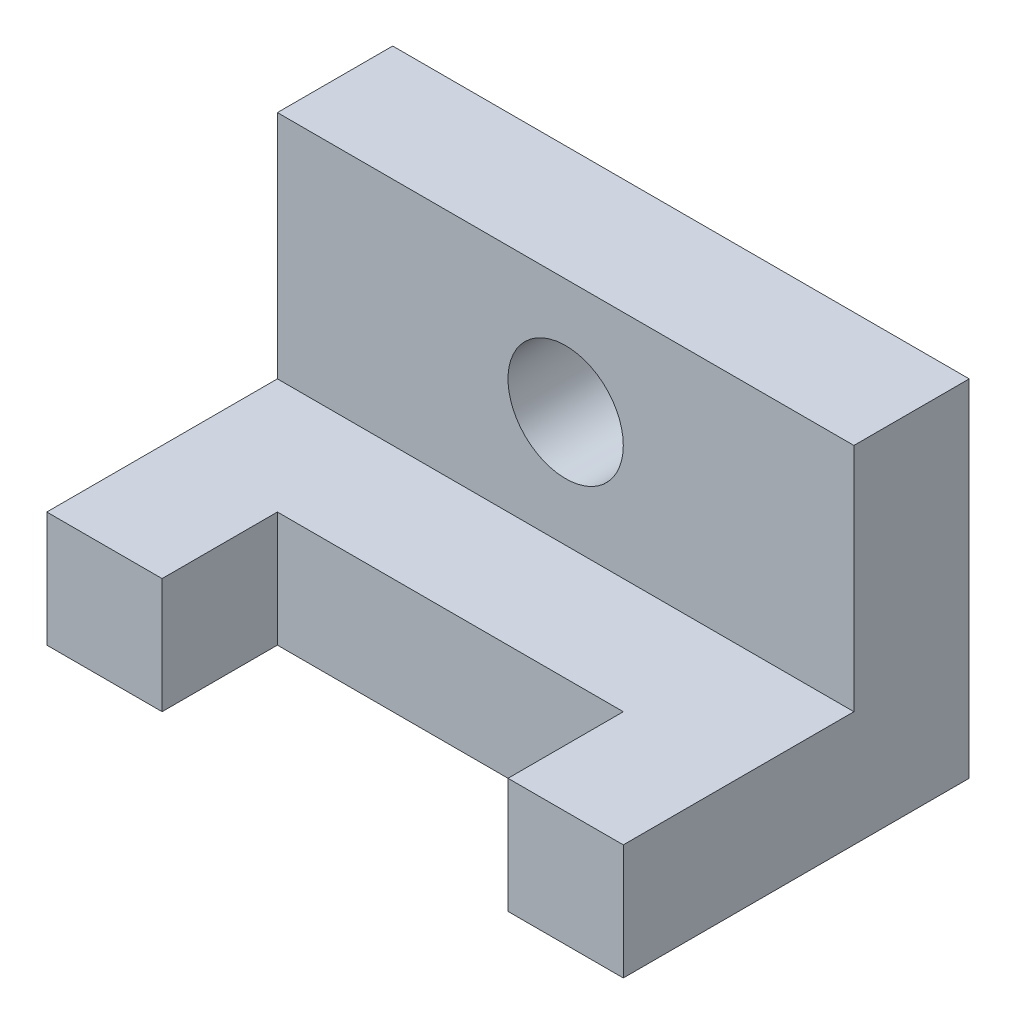
from build123d import *

# Parameters (mm, degrees)
BOSS_EXTRUDE1_DEPTH = 20
SKETCH1_3_W         = 100
SKETCH1_3_H         = 20
BOSS_EXTRUDE2_DEPTH = 60
SKETCH2_R           = 10
CUT_EXTRUDE1_DEPTH  = 124.288280059


with BuildPart() as part:
    # Sketch1 → Boss-Extrude1 (new body)
    with BuildSketch(Plane(origin=(0, 0, 0), x_dir=(1, 0, 0), z_dir=(0, 1, 0))):
        Polygon((0, 40), (0, 0), (20, 0), (20, 20), (80, 20), (80, 0), (100, 0), (100, 40), align=None)
    extrude(amount=BOSS_EXTRUDE1_DEPTH)

    # Sketch1_3 → Boss-Extrude2 (add)
    with BuildSketch(Plane(origin=(0, 0, 0), x_dir=(1, 0, 0), z_dir=(0, 1, 0))):
        with Locations((50, 50)):
            Rectangle(SKETCH1_3_W, SKETCH1_3_H)
    extrude(amount=BOSS_EXTRUDE2_DEPTH)

    # Sketch2 → Cut-Extrude1 (cut, through all)
    with BuildSketch(Plane.XY.offset(-40)):
        with Locations((50, 40)):
            Circle(SKETCH2_R)
    extrude(amount=-CUT_EXTRUDE1_DEPTH, mode=Mode.SUBTRACT)


solid = part.part
